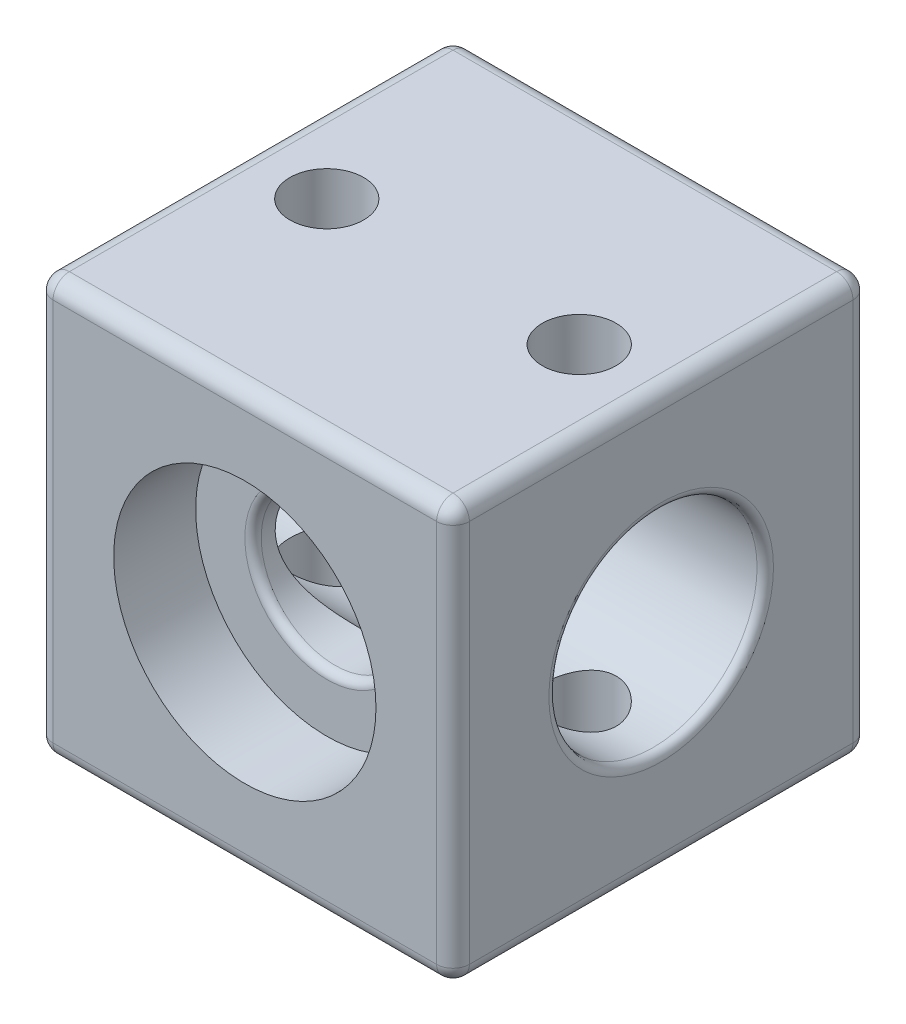
from build123d import *

# Parameters (mm, degrees)
SKETCH1_W           = 25.4
SKETCH1_H           = 25.4
SKETCH1_R           = 6.35
BOSS_EXTRUDE1_DEPTH = 25.4
SKETCH2_R           = 8
CUT_EXTRUDE2_DEPTH  = 5
SKETCH3_R           = 4.5
CUT_EXTRUDE3_DEPTH  = 44
FILLET1_R           = 1
FILLET2_R           = 0.5
SKETCH4_R           = 2.25
CUT_EXTRUDE4_DEPTH  = 44
CUT_EXTRUDE5_DEPTH  = 1


with BuildPart() as part:
    # Sketch1 → Boss-Extrude1 (new body)
    with BuildSketch(Plane(origin=(0, 0, 0), x_dir=(0, 0, -1), z_dir=(1, 0, 0))):
        Rectangle(SKETCH1_W, SKETCH1_H)
        Circle(SKETCH1_R, mode=Mode.SUBTRACT)
    extrude(amount=BOSS_EXTRUDE1_DEPTH)

    # Sketch2 → Cut-Extrude2 (cut)
    with BuildSketch(Plane.XY.offset(12.7)):
        with Locations((12.7, 0)):
            Circle(SKETCH2_R)
    cut_extrude2 = extrude(amount=-CUT_EXTRUDE2_DEPTH, mode=Mode.SUBTRACT)

    # Mirror1: Cut-Extrude2 across plane
    add(cut_extrude2.mirror(Plane.XY), mode=Mode.SUBTRACT)

    # Sketch3 → Cut-Extrude3 (cut)
    with BuildSketch(Plane.XY.offset(7.7)):
        with Locations((12.7, 0)):
            Circle(SKETCH3_R)
    extrude(amount=-CUT_EXTRUDE3_DEPTH, mode=Mode.SUBTRACT)

    # Fillet1
    fillet1_edges = [part.edges().sort_by_distance(p)[0] for p in [
        (25.4, 0, -12.7),
        (25.4, 12.7, 0),
        (25.4, 0, 12.7),
        (0, 12.7, 0),
        (0, 0, -12.7),
        (0, -12.7, 0),
        (0, 0, 12.7),
        (12.7, 12.7, 12.7),
        (12.7, 12.7, -12.7),
        (12.7, -12.7, -12.7),
        (12.7, -12.7, 12.7),
        (25.4, -12.7, 0),
    ]]
    fillet(fillet1_edges, radius=FILLET1_R)

    # Fillet2
    fillet2_edges = [part.edges().sort_by_distance(p)[0] for p in [
        (0, 0, 6.35),
        (25.4, 0, 6.35),
        (8.2, 0, -7.7),
        (8.2, 0, 7.7),
    ]]
    fillet(fillet2_edges, radius=FILLET2_R)

    # Sketch4 → Cut-Extrude4 (cut)
    with BuildSketch(Plane(origin=(0, 12.7, 0), x_dir=(1, 0, 0), z_dir=(0, 1, 0))):
        with Locations((5, 0)):
            Circle(SKETCH4_R)
        with Locations((20.4, 0)):
            Circle(SKETCH4_R)
    extrude(amount=-CUT_EXTRUDE4_DEPTH, mode=Mode.SUBTRACT)

    # Sketch5 → Cut-Extrude5 (cut)
    with BuildSketch(Plane.XZ.offset(12.7)):
        Polygon((9, 2.309401077), (5, 4.618802154), (1, 2.309401077), (1, -2.309401077), (5, -4.618802154), (9, -2.309401077), align=None)
        Polygon((20.4, 4.618802154), (16.4, 2.309401077), (16.4, -2.309401077), (20.4, -4.618802154), (24.4, -2.309401077), (24.4, 2.309401077), align=None)
    extrude(amount=-CUT_EXTRUDE5_DEPTH, mode=Mode.SUBTRACT)


solid = part.part
